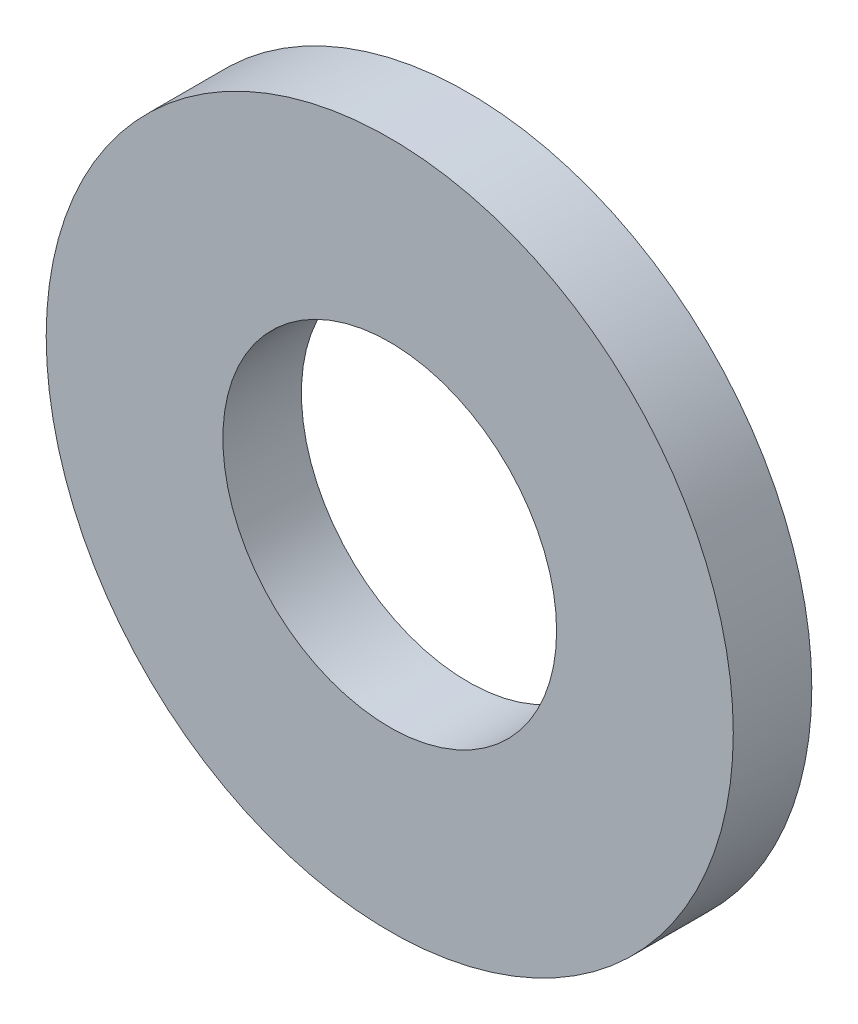
from build123d import *

# Parameters (mm, degrees)
ESQUISSE1_R        = 3.5
ESQUISSE1_R_2      = 1.7
BOSS_EXTRU_1_DEPTH = 0.8


with BuildPart() as part:
    # Esquisse1 → Boss.-Extru.1 (new body)
    with BuildSketch(Plane.XY):
        Circle(ESQUISSE1_R)
        Circle(ESQUISSE1_R_2, mode=Mode.SUBTRACT)
    extrude(amount=BOSS_EXTRU_1_DEPTH)


solid = part.part
